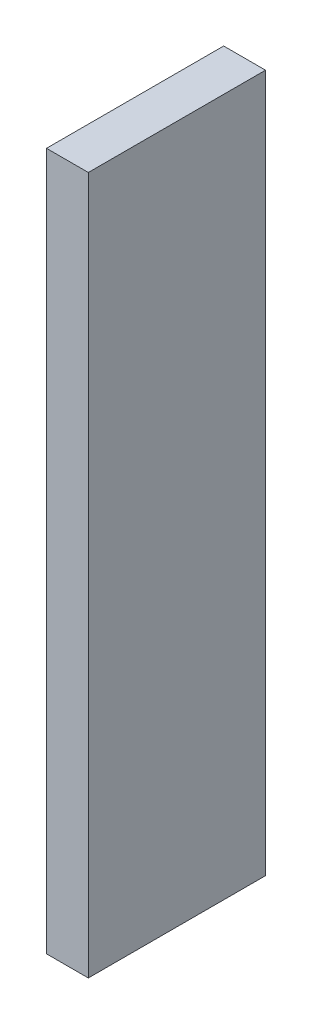
from build123d import *

# Parameters (mm, degrees)
SKETCH1_W           = 1.5
SKETCH1_H           = 6.35
BOSS_EXTRUDE1_DEPTH = 25


with BuildPart() as part:
    # Sketch1 → Boss-Extrude1 (new body)
    with BuildSketch(Plane(origin=(0, 0, 0), x_dir=(1, 0, 0), z_dir=(0, 1, 0))):
        Rectangle(SKETCH1_W, SKETCH1_H)
    extrude(amount=BOSS_EXTRUDE1_DEPTH)


solid = part.part
